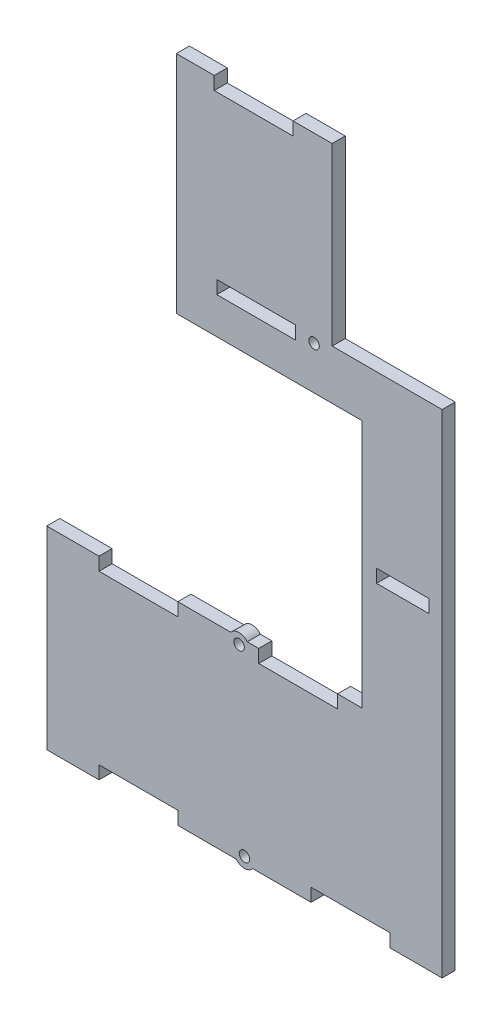
from build123d import *

# Parameters (mm, degrees)
SKETCH1_W           = 151
SKETCH1_H           = 255
BOSS_EXTRUDE1_DEPTH = 5
SKETCH2_W           = 49.486524855
SKETCH2_H           = 99.222786378
CUT_EXTRUDE1_DEPTH  = 5
SKETCH3_W           = 42
SKETCH3_H           = 67
CUT_EXTRUDE2_DEPTH  = 5
SKETCH4_W           = 120.35
SKETCH4_H           = 95.04721362
CUT_EXTRUDE3_DEPTH  = 5
SKETCH5_W           = 30.1
SKETCH5_H           = 5
SKETCH5_W_2         = 20.1
SKETCH5_H_2         = 5.016666667
CUT_EXTRUDE4_DEPTH  = 5
SKETCH6_R           = 2
CUT_EXTRUDE5_DEPTH  = 10
SKETCH8_R           = 4
SKETCH8_R_2         = 2
BOSS_EXTRUDE2_DEPTH = 5


with BuildPart() as part:
    # Sketch1 → Boss-Extrude1 (new body)
    with BuildSketch(Plane.XY):
        Rectangle(SKETCH1_W, SKETCH1_H)
    extrude(amount=BOSS_EXTRUDE1_DEPTH)

    # Sketch2 → Cut-Extrude1 (cut)
    with BuildSketch(Plane.XY.offset(5)):
        with Locations((-50.756737573, 77.888606811)):
            Rectangle(SKETCH2_W, SKETCH2_H)
    extrude(amount=-CUT_EXTRUDE1_DEPTH, mode=Mode.SUBTRACT)

    # Sketch3 → Cut-Extrude2 (cut)
    with BuildSketch(Plane.XY.offset(5)):
        with Locations((54.5, 94)):
            Rectangle(SKETCH3_W, SKETCH3_H)
    extrude(amount=-CUT_EXTRUDE2_DEPTH, mode=Mode.SUBTRACT)

    # Sketch4 → Cut-Extrude3 (cut)
    with BuildSketch(Plane.XY.offset(5)):
        with Locations((-15.325, -5.976393188)):
            Rectangle(SKETCH4_W, SKETCH4_H)
    extrude(amount=-CUT_EXTRUDE3_DEPTH, mode=Mode.SUBTRACT)

    # Sketch5 → Cut-Extrude4 (cut)
    with BuildSketch(Plane.XY.offset(5)):
        with Locations((40.5, -125)):
            Rectangle(SKETCH5_W, SKETCH5_H)
        with Locations((-40.5, -125)):
            Rectangle(SKETCH5_W, SKETCH5_H)
        with Locations((20.5, -56)):
            Rectangle(SKETCH5_W, SKETCH5_H)
        with Locations((-40.5, -56)):
            Rectangle(SKETCH5_W, SKETCH5_H)
        with Locations((60.5, -7)):
            Rectangle(SKETCH5_W_2, SKETCH5_H)
        with Locations((4.475, 58.004166666)):
            Rectangle(SKETCH5_W, SKETCH5_H_2)
        with Locations((3.5, 125)):
            Rectangle(SKETCH5_W, SKETCH5_H)
    extrude(amount=-CUT_EXTRUDE4_DEPTH, mode=Mode.SUBTRACT)

    # Sketch6 → Cut-Extrude5 (cut)
    with BuildSketch(Plane.XY.offset(5)):
        with Locations((0, -125)):
            Circle(SKETCH6_R)
        with Locations((-2.045010771, -56)):
            Circle(SKETCH6_R)
        with Locations((26.57851787, 58)):
            Circle(SKETCH6_R)
    extrude(amount=-CUT_EXTRUDE5_DEPTH, mode=Mode.SUBTRACT)

    # Sketch8 → Boss-Extrude2 (add)
    with BuildSketch(Plane.XY.offset(5)):
        with Locations((0, -125)):
            Circle(SKETCH8_R)
        with Locations((0, -125)):
            Circle(SKETCH8_R_2, mode=Mode.SUBTRACT)
        with Locations((-2.045010771, -56)):
            Circle(SKETCH8_R)
        with Locations((-2.045010771, -56)):
            Circle(SKETCH8_R_2, mode=Mode.SUBTRACT)
    extrude(amount=-BOSS_EXTRUDE2_DEPTH)


solid = part.part
